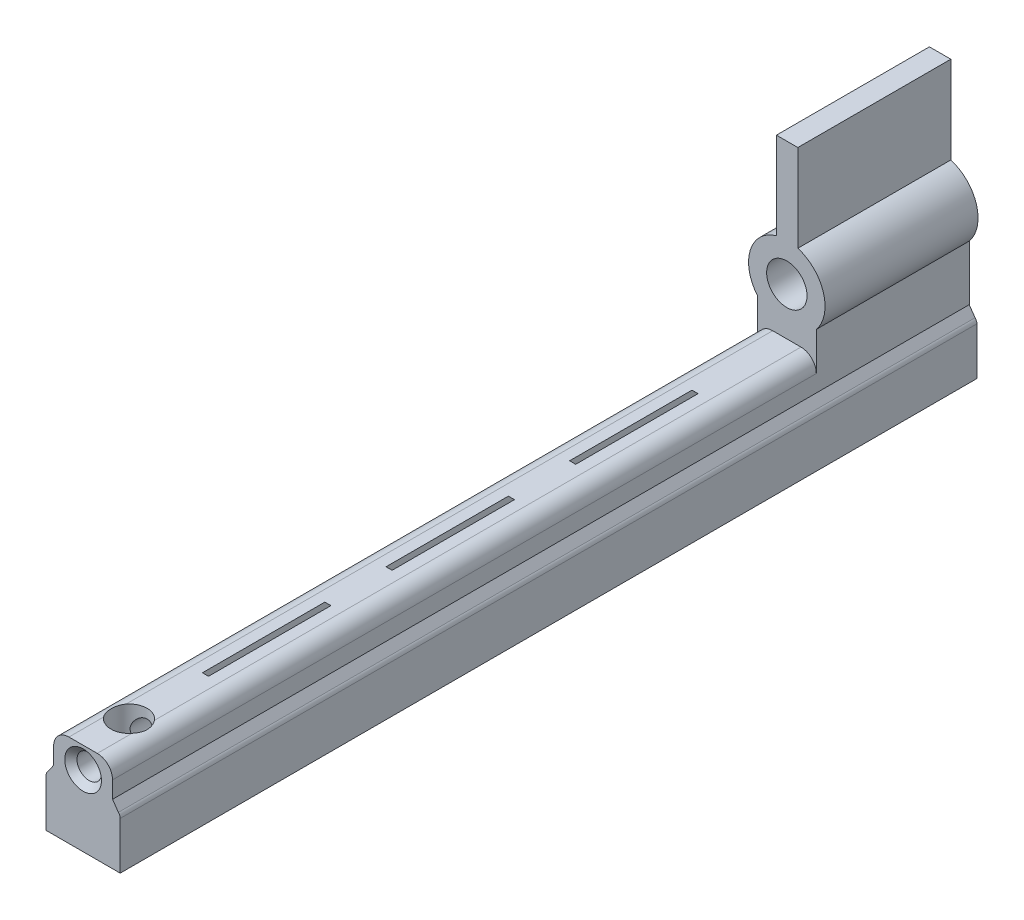
from build123d import *

# Parameters (mm, degrees)
SKETCH1_R                = 0.66
SKETCH1_R_2              = 0.4
BOSS_EXTRUDE1_DEPTH      = 4
BOSS_EXTRUDE1_DEPTH_BACK = 1
BOSS_EXTRUDE2_DEPTH      = 20
SKETCH8_R                = 0.4
BOSS_EXTRUDE3_DEPTH      = 3
BOSS_EXTRUDE3_DEPTH_BACK = 20
FILLET1_R                = 0.5
CUT_EXTRUDE4_START       = -4
CUT_EXTRUDE4_DEPTH       = 4
CUT_EXTRUDE5_START       = -10
CUT_EXTRUDE5_DEPTH       = 4
CUT_EXTRUDE6_START       = -16
CUT_EXTRUDE6_DEPTH       = 4
CUT_EXTRUDE7_DEPTH       = 0.2
CHAMFER1_SIZE            = 0.2
CUT_EXTRUDE9_START       = -22
CUT_EXTRUDE9_DEPTH       = 4
SKETCH17_R               = 0.59
CUT_EXTRUDE11_DEPTH      = 9.61358644


with BuildPart() as part:
    # Sketch1 → Boss-Extrude1 (new body, two sides)
    with BuildSketch(Plane.XY) as boss_extrude1_sk:
        with BuildLine():
            Line((-0.962751438, 1.153198745), (-1.154172794, 0.877795696))
            ThreePointArc((-1.154172794, 0.877795696), (-1.197527345, 0.812911026), (-1.212751438, 0.73637434))
            Line((-1.212751438, 0.73637434), (-1.212751438, -0.81362566))
            Line((-1.212751438, -0.81362566), (0.95, -0.81362566))
            Line((0.95, -0.81362566), (1.2, -0.81362566))
            Line((1.2, -0.81362566), (1.212751438, -0.81362566))
            Line((1.212751438, -0.81362566), (1.212751438, 0.73637434))
            ThreePointArc((1.212751438, 0.73637434), (1.197527345, 0.812911026), (1.154172794, 0.877795696))
            Line((1.154172794, 0.877795696), (0.962751438, 1.153198745))
            Line((0.962751438, 1.153198745), (0.962751438, 2.952748679))
            ThreePointArc((0.962751438, 2.952748679), (1.196528268, 4.111690618), (0.359901995, 4.947067481))
            Line((0.359901995, 4.947067481), (0.359901995, 7.79996078))
            Line((0.359901995, 7.79996078), (-0.340098005, 7.79996078))
            Line((-0.340098005, 7.79996078), (-0.340098005, 4.952843858))
            ThreePointArc((-0.340098005, 4.952843858), (-1.193502974, 4.12155168), (-0.962751438, 2.952748679))
            Line((-0.962751438, 2.952748679), (-0.962751438, 1.153198745))
        make_face()
        with Locations((0, 3.75)):
            Circle(SKETCH1_R, mode=Mode.SUBTRACT)
        with Locations((0, 1.5)):
            Circle(SKETCH1_R_2, mode=Mode.SUBTRACT)
    extrude(amount=BOSS_EXTRUDE1_DEPTH)
    extrude(boss_extrude1_sk.sketch, amount=-BOSS_EXTRUDE1_DEPTH_BACK)

    # Sketch7 → Boss-Extrude2 (add)
    with BuildSketch(Plane.XY.offset(4)):
        with BuildLine():
            Line((-1.154172794, 0.877795696), (1.154172794, 0.877795696))
            ThreePointArc((1.154172794, 0.877795696), (1.197527345, 0.812911026), (1.212751438, 0.73637434))
            Line((1.212751438, 0.73637434), (1.212751438, -0.81362566))
            Line((1.212751438, -0.81362566), (-1.212751438, -0.81362566))
            Line((-1.212751438, -0.81362566), (-1.212751438, 0.73637434))
            ThreePointArc((-1.212751438, 0.73637434), (-1.197527345, 0.812911026), (-1.154172794, 0.877795696))
        make_face()
    extrude(amount=BOSS_EXTRUDE2_DEPTH)

    # Sketch8 → Boss-Extrude3 (add, two sides)
    with BuildSketch(Plane.XY.offset(24)) as boss_extrude3_sk:
        with BuildLine():
            Line((-1.212751438, 0.73637434), (-1.212751438, -0.81362566))
            Line((-1.212751438, -0.81362566), (1.212751438, -0.81362566))
            Line((1.212751438, -0.81362566), (1.212751438, 0.73637434))
            ThreePointArc((1.212751438, 0.73637434), (1.197527345, 0.812911026), (1.154172794, 0.877795696))
            Line((1.154172794, 0.877795696), (0.962751438, 1.153198745))
            Line((0.962751438, 1.153198745), (0.962751438, 2.202748679))
            Line((0.962751438, 2.202748679), (-0.962751438, 2.202748679))
            Line((-0.962751438, 2.202748679), (-0.962751438, 1.153198745))
            Line((-0.962751438, 1.153198745), (-1.154172794, 0.877795696))
            ThreePointArc((-1.154172794, 0.877795696), (-1.197527345, 0.812911026), (-1.212751438, 0.73637434))
        make_face()
        with Locations((0, 1.5)):
            Circle(SKETCH8_R, mode=Mode.SUBTRACT)
    extrude(amount=BOSS_EXTRUDE3_DEPTH)
    extrude(boss_extrude3_sk.sketch, amount=-BOSS_EXTRUDE3_DEPTH_BACK)

    # Fillet1
    fillet1_edges = [part.edges().sort_by_distance(p)[0] for p in [
        (-0.962751438, 2.202748679, 15.5),
        (0.962751438, 2.202748679, 15.5),
    ]]
    fillet(fillet1_edges, radius=FILLET1_R)

    # Sketch10 → Cut-Extrude4 (cut)
    with BuildSketch(Plane.XY.offset(27).offset(CUT_EXTRUDE4_START)):
        Polygon((0, 2.202748679), (0.1, 2.202748679), (0.1, 1.887298335), (-0.1, 1.887298335), (-0.1, 2.202748679), align=None)
    extrude(amount=-CUT_EXTRUDE4_DEPTH, mode=Mode.SUBTRACT)

    # Sketch10_2 → Cut-Extrude5 (cut)
    with BuildSketch(Plane.XY.offset(27).offset(CUT_EXTRUDE5_START)):
        Polygon((0, 2.202748679), (0.1, 2.202748679), (0.1, 1.887298335), (-0.1, 1.887298335), (-0.1, 2.202748679), align=None)
    extrude(amount=-CUT_EXTRUDE5_DEPTH, mode=Mode.SUBTRACT)

    # Sketch10_3 → Cut-Extrude6 (cut)
    with BuildSketch(Plane.XY.offset(27).offset(CUT_EXTRUDE6_START)):
        Polygon((0, 2.202748679), (0.1, 2.202748679), (0.1, 1.887298335), (-0.1, 1.887298335), (-0.1, 2.202748679), align=None)
    extrude(amount=-CUT_EXTRUDE6_DEPTH, mode=Mode.SUBTRACT)

    # Sketch11 → Cut-Extrude7 (cut)
    with BuildSketch(Plane.ZY.offset(-0.1)):
        Polygon((13, 2.202748679), (13, 1.887298335), (12.65, 1.887298335), align=None)
        Polygon((19, 2.202748679), (19, 1.887298335), (18.65, 1.887298335), align=None)
        Polygon((7.000738825, 2.202748679), (7.000738825, 1.887298335), (6.650738825, 1.887298335), align=None)
    extrude(amount=CUT_EXTRUDE7_DEPTH, mode=Mode.SUBTRACT)

    # Chamfer1
    chamfer1_edges = [part.edges().sort_by_distance(p)[0] for p in [
        (-0.4, 1.5, 27),
    ]]
    chamfer(chamfer1_edges, length=CHAMFER1_SIZE)

    # Sketch14 → Cut-Extrude9 (cut)
    with BuildSketch(Plane.XY.offset(27).offset(CUT_EXTRUDE9_START)):
        Polygon((0.2, 1.1), (0.2, -0.81362566), (-0.2, -0.81362566), (-0.2, 1.1), (-0.2, 1.254612966), (0, 1.254612966), (0.2, 1.254612966), align=None)
    extrude(amount=-CUT_EXTRUDE9_DEPTH, mode=Mode.SUBTRACT)

    # Sketch17 → Cut-Extrude11 (cut, through all)
    with BuildSketch(Plane.XZ.offset(0.81362566)):
        with Locations(Location((0, 25.5, 0), (0, 0, 270))):  # turned: the seam where the file's is
            Circle(SKETCH17_R)
    extrude(amount=-CUT_EXTRUDE11_DEPTH, mode=Mode.SUBTRACT)


solid = part.part
